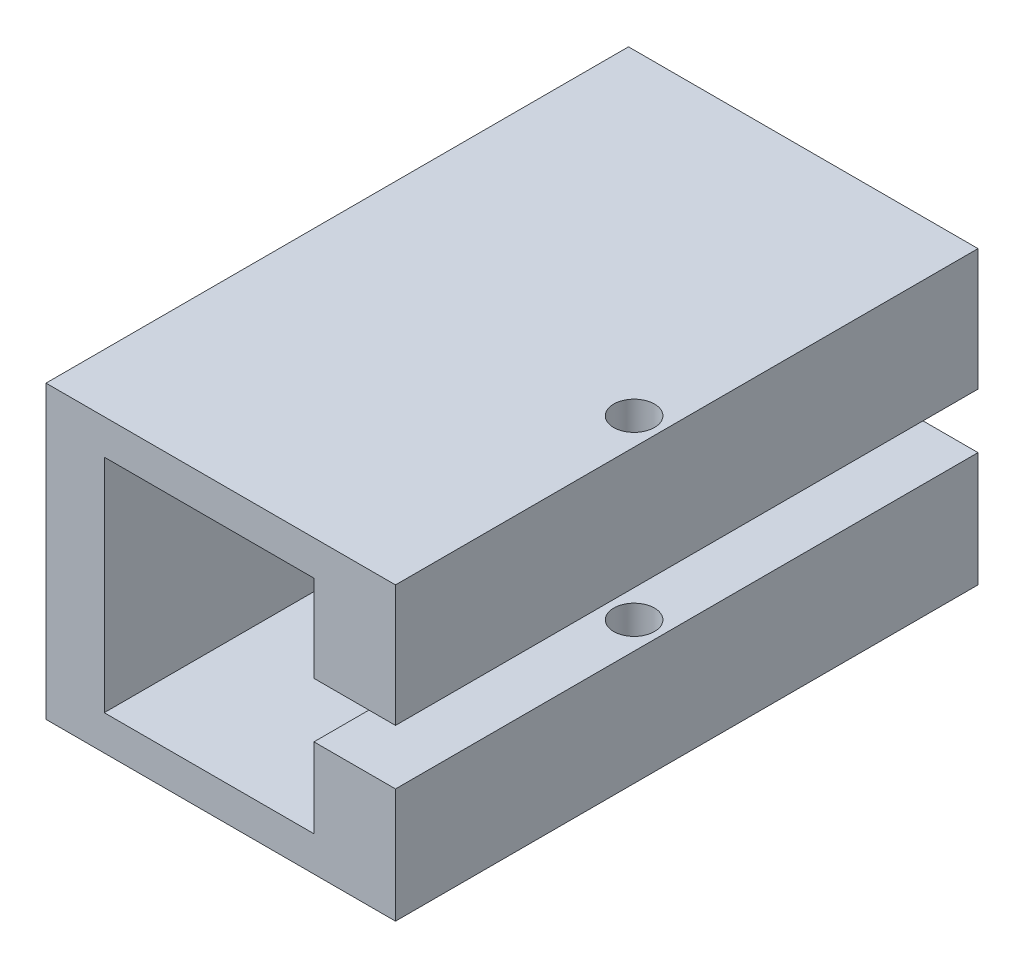
from build123d import *

# Parameters (mm, degrees)
BOSS_EXTRUDE1_DEPTH = 50
SKETCH3_R           = 0.55
CUT_EXTRUDE1_DEPTH  = 3
SKETCH4_R           = 1.75
CUT_EXTRUDE2_DEPTH  = 26


with BuildPart() as part:
    # Sketch1 → Boss-Extrude1 (new body)
    with BuildSketch(Plane.XY):
        Polygon((0, 0), (0, 25), (30, 25), (30, 14.553417219), (23, 14.553417219), (23, 22), (5, 22), (5, 3), (23, 3), (23, 9.833225485), (30, 9.833225485), (30, 0), align=None)
    extrude(amount=BOSS_EXTRUDE1_DEPTH)

    # Sketch3 → Cut-Extrude1 (cut)
    with BuildSketch(Plane.ZY):
        Polygon((4.919472148, 16.056705519), (21.919472148, 16.056705519), (21.919472148, 24.056705519), (27.919472148, 24.056705519), (27.919472148, 16.056705519), (42.919472148, 16.056705519), (42.919472148, 9.056705519), (27.919472148, 9.056705519), (27.919472148, 1.056705519), (21.919472148, 1.056705519), (21.919472148, 9.056705519), (4.919472148, 9.056705519), align=None)
        with Locations((40.25, 12.520312642)):
            Circle(SKETCH3_R, mode=Mode.SUBTRACT)
        with Locations((8.980224058, 12.520312642)):
            Circle(SKETCH3_R, mode=Mode.SUBTRACT)
    extrude(amount=-CUT_EXTRUDE1_DEPTH, mode=Mode.SUBTRACT)

    # Sketch4 → Cut-Extrude2 (cut)
    with BuildSketch(Plane(origin=(0, 25, 0), x_dir=(1, 0, 0), z_dir=(0, 1, 0))):
        with Locations((27.668171427, -27.18874166)):
            Circle(SKETCH4_R)
    extrude(amount=-CUT_EXTRUDE2_DEPTH, mode=Mode.SUBTRACT)


solid = part.part
